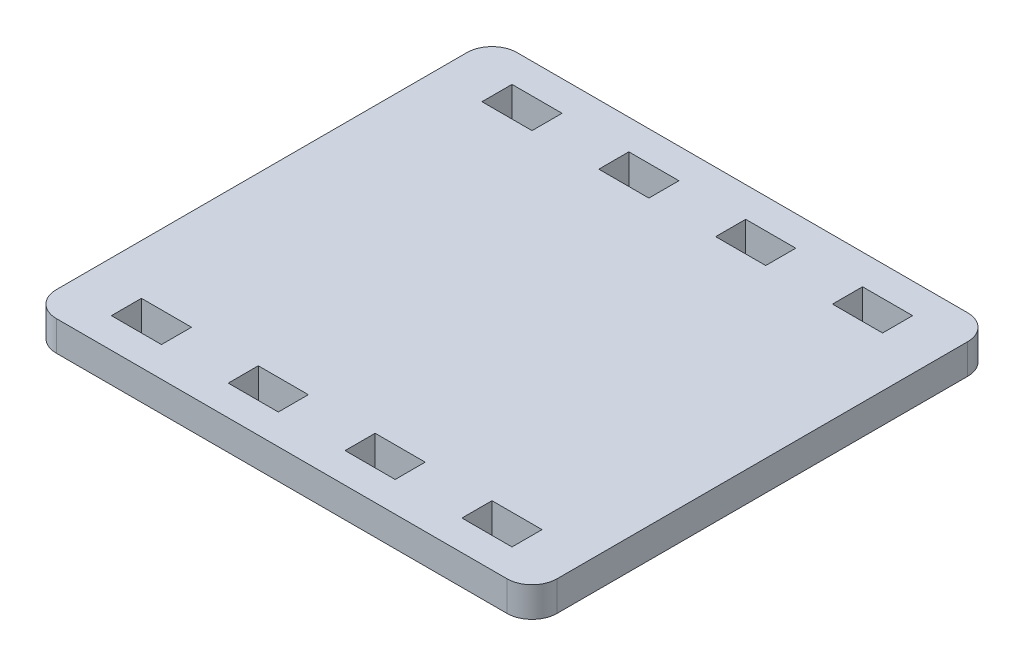
from build123d import *

# Parameters (mm, degrees)
SKETCH1_W           = 100
SKETCH1_H           = 92
BOSS_EXTRUDE1_DEPTH = 6
SKETCH6_W           = 10
SKETCH6_H           = 6
CUT_EXTRUDE1_DEPTH  = 4
SKETCH61_W          = 10
SKETCH61_H          = 6
CUT_EXTRUDE11_DEPTH = 4
SKETCH62_W          = 10
SKETCH62_H          = 6
CUT_EXTRUDE12_DEPTH = 4
SKETCH63_W          = 10
SKETCH63_H          = 6
CUT_EXTRUDE13_DEPTH = 4
FILLET1_R           = 5


with BuildPart() as part:
    # Sketch1 → Boss-Extrude1 (new body)
    with BuildSketch(Plane(origin=(0, 0, 0), x_dir=(1, 0, 0), z_dir=(0, 1, 0))):
        with Locations((50, 46)):
            Rectangle(SKETCH1_W, SKETCH1_H)
    extrude(amount=BOSS_EXTRUDE1_DEPTH)

    # Sketch6 → Cut-Extrude1 (cut, symmetric)
    with BuildSketch(Plane(origin=(84.232221392, 3, -39), x_dir=(1, 0, 0), z_dir=(0, -1, 0))):
        with Locations((0.767778608, -44)):
            Rectangle(SKETCH6_W, SKETCH6_H)
    cut_extrude1 = extrude(amount=CUT_EXTRUDE1_DEPTH, both=True, mode=Mode.SUBTRACT)

    # Sketch61 → Cut-Extrude11 (cut, symmetric)
    with BuildSketch(Plane(origin=(60.898888059, 3, -39), x_dir=(1, 0, 0), z_dir=(0, -1, 0))):
        with Locations((0.767778608, -44)):
            Rectangle(SKETCH61_W, SKETCH61_H)
    cut_extrude11 = extrude(amount=CUT_EXTRUDE11_DEPTH, both=True, mode=Mode.SUBTRACT)

    # Sketch62 → Cut-Extrude12 (cut, symmetric)
    with BuildSketch(Plane(origin=(37.565554726, 3, -39), x_dir=(1, 0, 0), z_dir=(0, -1, 0))):
        with Locations((0.767778608, -44)):
            Rectangle(SKETCH62_W, SKETCH62_H)
    cut_extrude12 = extrude(amount=CUT_EXTRUDE12_DEPTH, both=True, mode=Mode.SUBTRACT)

    # Sketch63 → Cut-Extrude13 (cut, symmetric)
    with BuildSketch(Plane(origin=(14.232221392, 3, -39), x_dir=(1, 0, 0), z_dir=(0, -1, 0))):
        with Locations((0.767778608, -44)):
            Rectangle(SKETCH63_W, SKETCH63_H)
    cut_extrude13 = extrude(amount=CUT_EXTRUDE13_DEPTH, both=True, mode=Mode.SUBTRACT)

    # Mirror1: Cut-Extrude1, Cut-Extrude11, Cut-Extrude12, Cut-Extrude13 across plane
    add(cut_extrude1.mirror(Plane(origin=(0, 0, -46), x_dir=(1, 0, 0), z_dir=(0, 0, -1))), mode=Mode.SUBTRACT)
    add(cut_extrude11.mirror(Plane(origin=(0, 0, -46), x_dir=(1, 0, 0), z_dir=(0, 0, -1))), mode=Mode.SUBTRACT)
    add(cut_extrude12.mirror(Plane(origin=(0, 0, -46), x_dir=(1, 0, 0), z_dir=(0, 0, -1))), mode=Mode.SUBTRACT)
    add(cut_extrude13.mirror(Plane(origin=(0, 0, -46), x_dir=(1, 0, 0), z_dir=(0, 0, -1))), mode=Mode.SUBTRACT)

    # Fillet1
    fillet1_edges = [part.edges().sort_by_distance(p)[0] for p in [
        (0, 3, -92),
        (100, 3, -92),
        (100, 3, 0),
        (0, 3, 0),
    ]]
    fillet(fillet1_edges, radius=FILLET1_R)


solid = part.part
